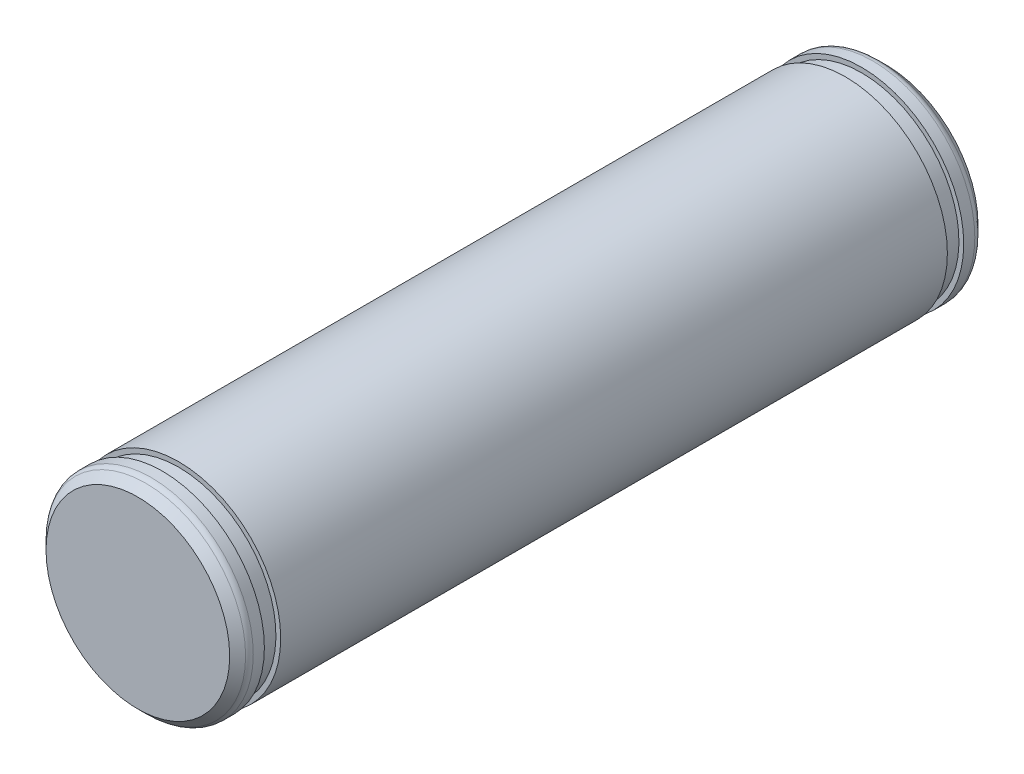
from build123d import *

# Parameters (mm, degrees)
SKETCH3_R           = 7.5
BOSS_EXTRUDE1_DEPTH = 27.5
CHAMFER1_SIZE       = 0.75
FILLET2_R           = 0.5625
SKETCH4_W           = 1.2
SKETCH4_H           = 0.35


with BuildPart() as part:
    # Sketch3 → Boss-Extrude1 (new, symmetric)
    with BuildSketch(Plane.XY):
        Circle(SKETCH3_R)
    extrude(amount=BOSS_EXTRUDE1_DEPTH, both=True)

    # Chamfer1
    chamfer1_edges = [part.edges().sort_by_distance(p)[0] for p in [
        (-7.5, 0, -27.5),
        (-7.5, 0, 27.5),
    ]]
    chamfer(chamfer1_edges, length=CHAMFER1_SIZE)

    # Fillet2
    fillet2_edges = [part.edges().sort_by_distance(p)[0] for p in [
        (-7.5, 0, -26.75),
        (-7.5, 0, 26.75),
    ]]
    fillet(fillet2_edges, radius=FILLET2_R)

    # Sketch4 → Cut-Revolve1 (revolve, cut)
    with BuildSketch(Plane(origin=(0, 0, 0), x_dir=(0, 0, -1), z_dir=(1, 0, 0))):
        with Locations((25.1, 7.325)):
            Rectangle(SKETCH4_W, SKETCH4_H)
    cut_revolve1 = revolve(axis=Axis((0, 0, -27.5), (0, 0, 1)), mode=Mode.SUBTRACT)

    # Mirror1: Cut-Revolve1 across plane
    add(cut_revolve1.mirror(Plane.XY), mode=Mode.SUBTRACT)


solid = part.part
